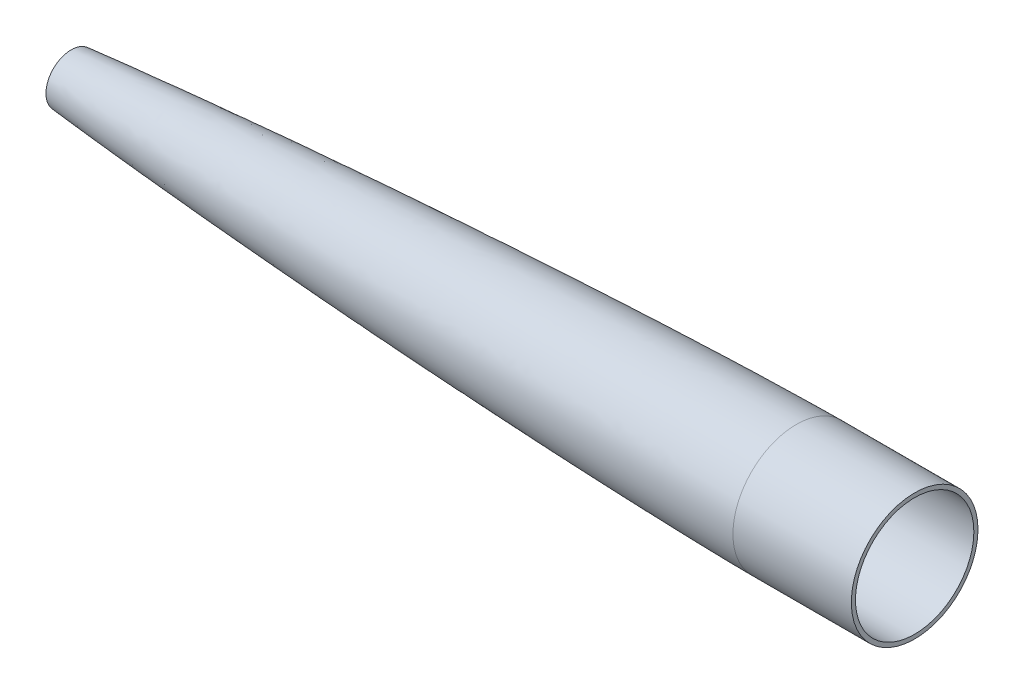
from build123d import *


with BuildPart() as part:
    # Sketch1 → Revolve1 (revolve)
    with BuildSketch(Plane.XY):
        with BuildLine():
            Line((380.999999989, 27.178004899), (431.8, 27.178))
            Line((431.8, 27.178), (431.8, 25.4))
            Line((431.8, 25.4), (381, 25.4))
            add(Edge.make_bspline(
                [(0, 0), (0.001941319, 0.003243823), (0.006382818, 0.00925202), (0.017667275, 0.019223361), (0.042247832, 0.036488891), (0.077859057, 0.057299108), (0.124666911, 0.081073388), (0.191190015, 0.111560456), (0.270954306, 0.144743138), (0.391141946, 0.190791694), (0.570606759, 0.253268093), (0.832648693, 0.336339412), (1.260148466, 0.459216902), (1.983126731, 0.646181326), (3.280775169, 0.943940876), (5.705080865, 1.430739778), (10.274282574, 2.223232896), (18.490307704, 3.442744834), (31.840039926, 5.137496754), (49.746942778, 7.09950102), (71.109771125, 9.167849109), (94.268578347, 11.185061055), (117.441592145, 13.030632407), (140.625521947, 14.733095675), (163.818284683, 16.310219347), (187.018536452, 17.77290183), (210.225327068, 19.127694121), (239.241159915, 20.690345726), (268.265978315, 22.078716552), (297.298940404, 23.286345214), (326.339718466, 24.285270316), (346.242146301, 24.843090738), (362.812447934, 25.19932343), (373.573868339, 25.350137429), (378.524571355, 25.394189211), (381, 25.4)],
                knots=[0, 0, 0, 0, 0, 3.9227e-05, 7.8455e-05, 0.00015691, 0.00031382, 0.000470729, 0.000627639, 0.000922762, 0.001217885, 0.001817749, 0.002616371, 0.003799723, 0.005873196, 0.009633205, 0.016550184, 0.029678517, 0.054408143, 0.096565334, 0.157394907, 0.218224481, 0.279054054, 0.339883628, 0.400713201, 0.461542775, 0.522372348, 0.583201922, 0.644031495, 0.765690643, 0.826520216, 0.88734979, 0.948179363, 0.974089682, 1, 1, 1, 1, 1], degree=4))
            Line((0, 0), (-1.525653687, 0))
            Line((-1.525653687, 0), (-1.525653687, 0.913052478))
            add(Edge.make_bspline(
                [(-1.525653687, 0.913052478), (-1.456861453, 1.028000006), (-1.26377196, 1.269904804), (-1.087429398, 1.412199762), (-1.013493249, 1.468214345), (-0.925784029, 1.528153174), (-0.855362465, 1.571407863), (-0.780983826, 1.613843829), (-0.72185978, 1.645154953), (-0.652016517, 1.68034405), (-0.578364938, 1.714904739), (-0.500498327, 1.749241532), (-0.40548642, 1.788962033), (-0.298594067, 1.830734515), (-0.179928297, 1.874274847), (-0.029341069, 1.926713817), (0.148530937, 1.984711708), (0.354249917, 2.047680173), (0.621686037, 2.125417369), (0.947815907, 2.214274016), (1.333040149, 2.312793076), (1.840853567, 2.436171773), (2.470214794, 2.579550949), (3.219855062, 2.739853891), (4.216537606, 2.942383064), (5.457677135, 3.178695266), (6.944501966, 3.444580978), (8.430077431, 3.696628333), (9.914523848, 3.937821961), (11.893289979, 4.247759303), (14.366835024, 4.616412883), (17.334891602, 5.035682182), (20.303074171, 5.436906223), (24.261618928, 5.951846532), (29.211245986, 6.562862372), (35.152484358, 7.256510838), (41.095684883, 7.918411303), (49.0222976, 8.764531441), (58.934081126, 9.764032687), (70.833127664, 10.891065768), (82.73619668, 11.957471963), (94.642742858, 12.972026646), (106.552294621, 13.940788983), (122.435308371, 15.177464154), (142.295120907, 16.629024918), (166.135030996, 18.239390464), (189.982086047, 19.729572133), (213.835604446, 21.106362176), (245.648268631, 22.794610058), (285.428933891, 24.629382357), (325.227005898, 26.060802219), (353.102253463, 26.781708154), (369.032405494, 27.070541833), (377.011809396, 27.168643072), (380.999999989, 27.178004899)],
                knots=[0, 0, 0, 0, 3.0518e-05, 6.1036e-05, 9.1554e-05, 0.000122072, 0.000183107, 0.000244143, 0.000305179, 0.000366215, 0.000488287, 0.000610358, 0.00073243, 0.000976573, 0.001220716, 0.00146486, 0.001953146, 0.002441433, 0.002929719, 0.003906293, 0.004882866, 0.005859439, 0.007812585, 0.009765732, 0.011718878, 0.015625171, 0.019531463, 0.023437756, 0.027344049, 0.031250341, 0.039062927, 0.046875512, 0.054688097, 0.062500683, 0.078125853, 0.093751024, 0.109376195, 0.125001365, 0.156251706, 0.187502048, 0.218752389, 0.25000273, 0.281253072, 0.312503413, 0.375004096, 0.437504778, 0.500005461, 0.562506143, 0.625006826, 0.750008191, 0.875009556, 0.937510239, 0.96876058, 1.000010921, 1.000010921, 1.000010921, 1.000010921], degree=3))
        make_face()
    revolve(axis=Axis((0, 0, 0), (-1, 0, 0)))

    # Split1
    split(bisect_by=Plane(origin=(69.85, 0, 0), x_dir=(0, 0, 1), z_dir=(1, 0, 0)), keep=Keep.TOP)


solid = part.part
